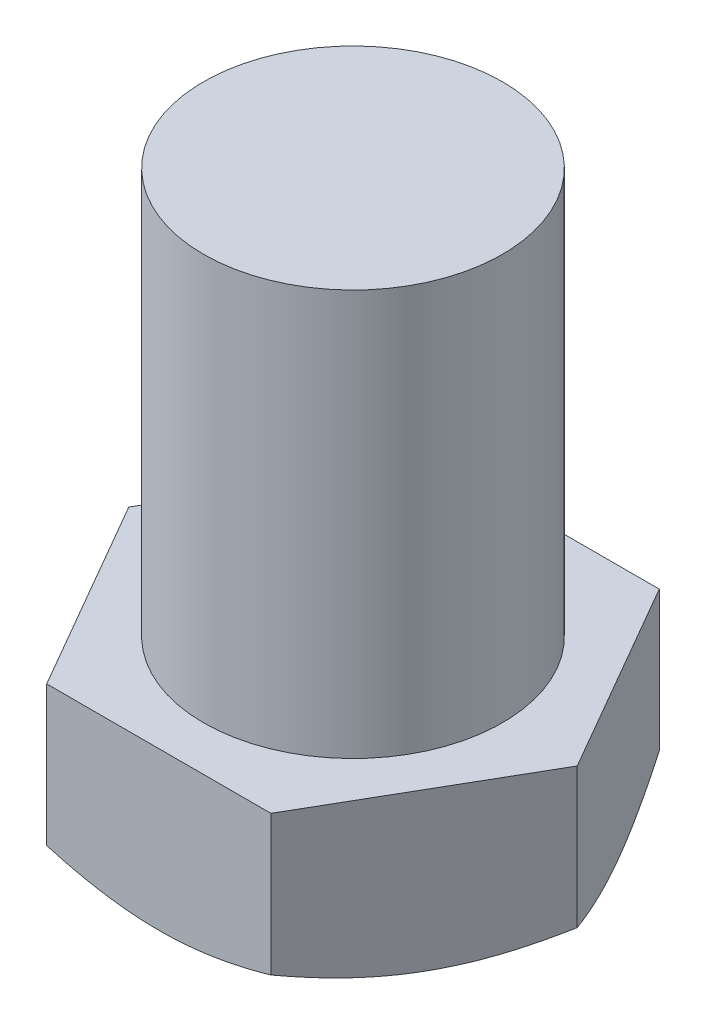
from build123d import *

# Parameters (mm, degrees)
EXTRUDE_1_DEPTH     = 8
SKETCH_2_R          = 7
EXTRUDE_2_DEPTH     = 19
SKETCH_3_OUTSIDE_W  = 35.944
SKETCH_3_OUTSIDE_H  = 33.13
SKETCH_3_OUTSIDE_R  = 8
CUT_EXTRUDE_2_DEPTH = 1.5
CUT_EXTRUDE_2_TAPER = 60


with BuildPart() as part:
    # Эскиз1 → Бобышка-Вытянуть1 (new body)
    with BuildSketch(Plane(origin=(0, 0, 0), x_dir=(1, 0, 0), z_dir=(0, 1, 0))):
        Polygon((10.5, 0), (5.25, 9.09326674), (-5.25, 9.09326674), (-10.5, 0), (-5.25, -9.09326674), (5.25, -9.09326674), align=None)
    extrude(amount=EXTRUDE_1_DEPTH)

    # Эскиз2 → Бобышка-Вытянуть2 (add)
    with BuildSketch(Plane(origin=(0, 8, 0), x_dir=(1, 0, 0), z_dir=(0, 1, 0))):
        Circle(SKETCH_2_R)
    extrude(amount=EXTRUDE_2_DEPTH)

    # Эскиз3 outside → Вырез-Вытянуть2 (cut)
    with BuildSketch(Plane.XZ):
        Rectangle(SKETCH_3_OUTSIDE_W, SKETCH_3_OUTSIDE_H)
        Circle(SKETCH_3_OUTSIDE_R, mode=Mode.SUBTRACT)
    extrude(amount=-CUT_EXTRUDE_2_DEPTH, taper=CUT_EXTRUDE_2_TAPER, mode=Mode.SUBTRACT)


solid = part.part
